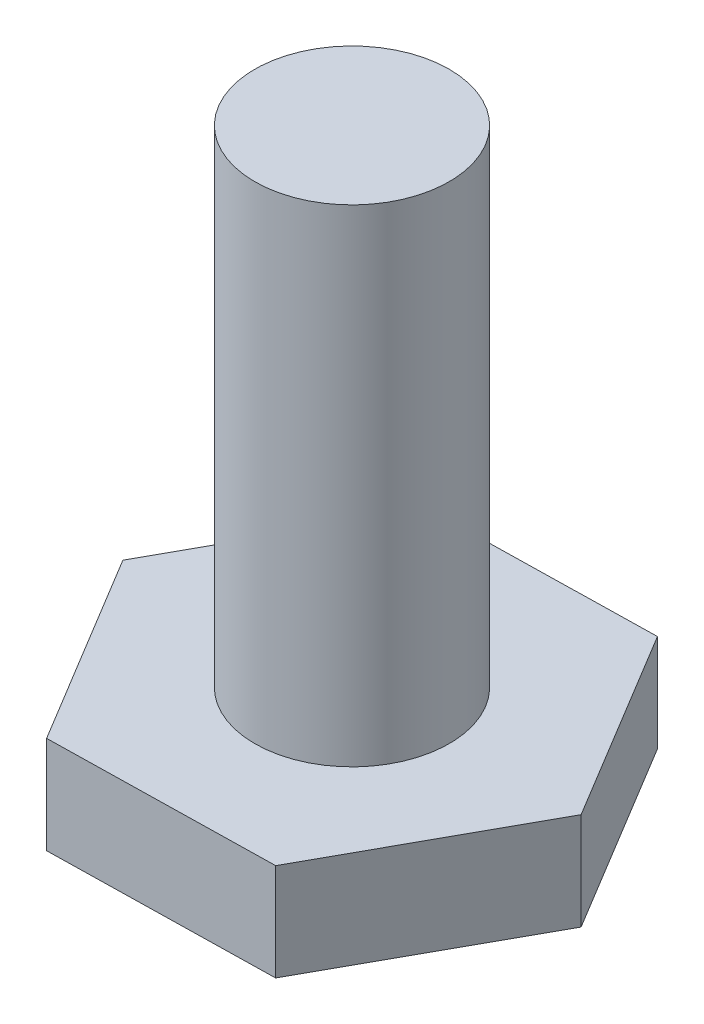
from build123d import *

# Parameters (mm, degrees)
SKETCH1_R           = 2
BOSS_EXTRUDE1_DEPTH = 10
BOSS_EXTRUDE4_DEPTH = 2


with BuildPart() as part:
    # Sketch1 → Boss-Extrude1 (new body)
    with BuildSketch(Plane(origin=(0, 0, 0), x_dir=(1, 0, 0), z_dir=(0, 1, 0))):
        with Locations((-18.876405997, -12.710678642)):
            Circle(SKETCH1_R)
    extrude(amount=BOSS_EXTRUDE1_DEPTH)

    # Sketch4 → Boss-Extrude4 (add)
    with BuildSketch(Plane.XZ):
        Polygon((-16.490145939, 16.665308368), (-21.108085773, 16.754555336), (-23.494345831, 12.79992561), (-21.262666056, 8.756048917), (-16.644726221, 8.666801949), (-14.258466163, 12.621431674), align=None)
    extrude(amount=BOSS_EXTRUDE4_DEPTH)


solid = part.part
